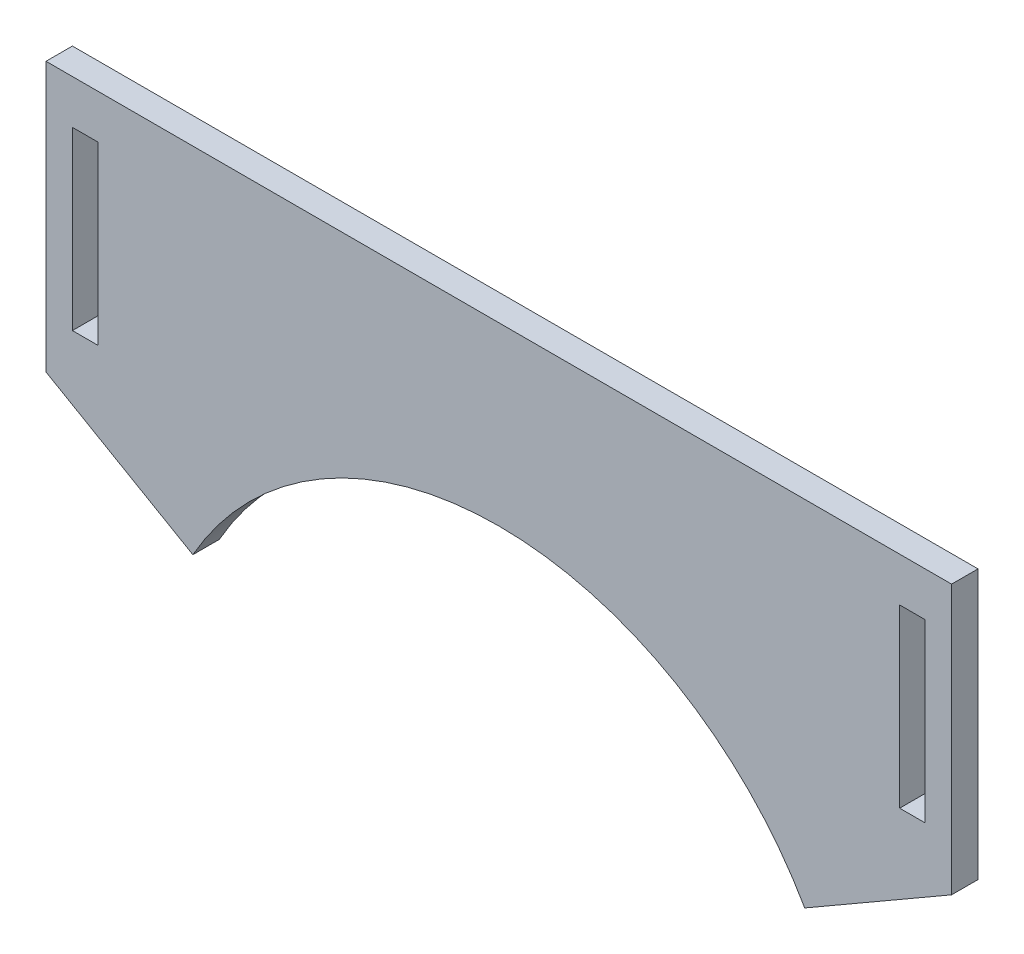
from build123d import *

# Parameters (mm, degrees)
SKETCH1_W           = 2.9
SKETCH1_H           = 20
BOSS_EXTRUDE1_DEPTH = 3
CUT_EXTRUDE1_DEPTH  = 4


with BuildPart() as part:
    # Sketch1 → Boss-Extrude1 (new body)
    with BuildSketch(Plane.XY):
        with BuildLine():
            Line((0, 0), (104.9, 0))
            Line((104.9, 0), (104.9, -30))
            Line((104.9, -30), (87.212489335, -40.211889044))
            ThreePointArc((87.212489335, -40.211889044), (52.45, -20), (17.687510665, -40.211889044))
            Line((17.687510665, -40.211889044), (0, -30))
            Line((0, -30), (0, 0))
        make_face()
        with Locations((99.45, -15)):
            Rectangle(SKETCH1_W, SKETCH1_H, mode=Mode.SUBTRACT)
        with Locations((5.45, -15)):
            Rectangle(SKETCH1_W, SKETCH1_H, mode=Mode.SUBTRACT)
    extrude(amount=BOSS_EXTRUDE1_DEPTH)

    # Sketch2 → Cut-Extrude1 (cut, through all)
    with BuildSketch(Plane.XY.offset(3)):
        Polygon((1, 0), (1, -30.577350269), (0, -30), (0, 0), align=None)
        Polygon((103.9, 0), (103.9, -30.577350269), (104.9, -30), (104.9, 0), align=None)
    extrude(amount=-CUT_EXTRUDE1_DEPTH, mode=Mode.SUBTRACT)


solid = part.part
